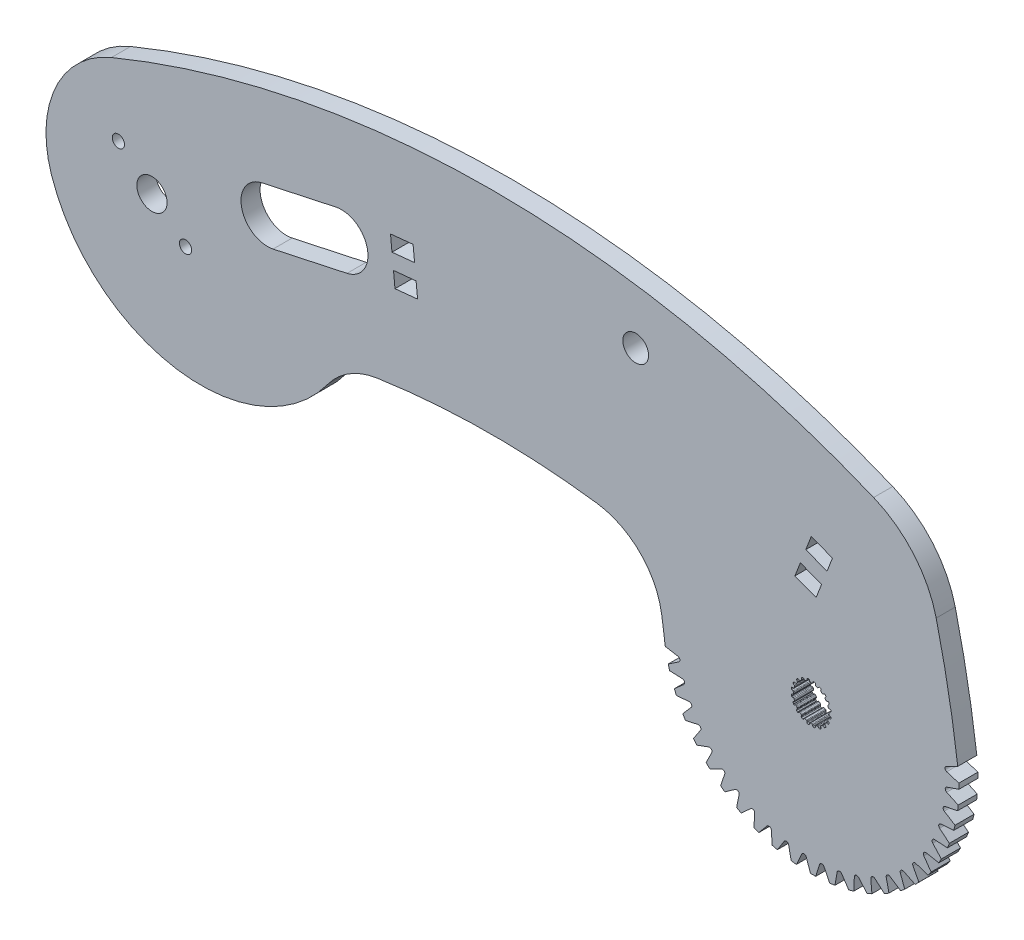
from build123d import *

# Parameters (mm, degrees)
BOSS_EXTRUDE1_DEPTH = 3.2004
BOSS_EXTRUDE2_DEPTH = 3.2004
SKETCH4_R           = 2.54
CUT_EXTRUDE1_DEPTH  = 3.2004
FILLET1_R           = 12.7
SKETCH8_R           = 1.025
CUT_EXTRUDE3_DEPTH  = 3.2004
CUT_EXTRUDE4_DEPTH  = 3.2004
BOSS_EXTRUDE3_DEPTH = 3.2004
CUT_EXTRUDE5_DEPTH  = 3.2004
SKETCH16_R          = 2.159
CUT_EXTRUDE6_DEPTH  = 3.2004


with BuildPart() as part:
    # Sketch1 → Boss-Extrude1 (new body)
    with BuildSketch(Plane.XY):
        with BuildLine():
            ThreePointArc((-6.790095085, 16.435726481), (57.15, 29.123460788), (121.090095085, 16.435726481))
            ThreePointArc((121.090095085, 16.435726481), (130.735726481, -6.790095085), (107.509904915, -16.435726481))
            ThreePointArc((107.509904915, -16.435726481), (57.15, -6.442730812), (6.790095085, -16.435726481))
            ThreePointArc((6.790095085, -16.435726481), (-16.435726481, -6.790095085), (-6.790095085, 16.435726481))
        make_face()
    extrude(amount=BOSS_EXTRUDE1_DEPTH)

    # Sketch3 → Boss-Extrude2 (add)
    with BuildSketch(Plane.XY.offset(3.2004)):
        with BuildLine():
            Line((83.379181354, -7.455358977), (131.587687265, 4.16825686))
            ThreePointArc((131.587687265, 4.16825686), (133.67003564, -5.652924646), (135.206099965, -15.574229365))
            ThreePointArc((135.206099965, -15.574229365), (113.721957777, -43.287328325), (86.008858395, -21.80318668))
            ThreePointArc((86.008858395, -21.80318668), (84.892525498, -14.592890619), (83.379181354, -7.455358977))
        make_face()
    extrude(amount=-BOSS_EXTRUDE2_DEPTH)

    # Sketch4 → Cut-Extrude1 (cut)
    with BuildSketch(Plane.XY.offset(3.2004)):
        Circle(SKETCH4_R)
        with BuildLine():
            Line((110.500529874, -15.718832607), (110.714428364, -15.718832607))
            ThreePointArc((110.714428364, -15.718832607), (110.803822332, -15.701783365), (110.861218357, -15.631160037))
            Line((110.861218357, -15.631160037), (110.923367267, -15.4511806))
            ThreePointArc((110.923367267, -15.4511806), (110.966511275, -15.390384629), (111.035624019, -15.362438535))
            Line((111.035624019, -15.362438535), (111.227506707, -15.394952841))
            ThreePointArc((111.227506707, -15.394952841), (111.297100261, -15.440681781), (111.325751331, -15.51887075))
            Line((111.325751331, -15.51887075), (111.331868286, -15.709180149))
            ThreePointArc((111.331868286, -15.709180149), (111.358413881, -15.784641441), (111.423506169, -15.831139498))
            Line((111.423506169, -15.831139498), (111.626935721, -15.897237766))
            ThreePointArc((111.626935721, -15.897237766), (111.717222943, -15.908647229), (111.793633615, -15.8592168))
            Line((111.793633615, -15.8592168), (111.908357445, -15.707251253))
            ThreePointArc((111.908357445, -15.707251253), (111.968176823, -15.662763081), (112.042542767, -15.657541778))
            Line((112.042542767, -15.657541778), (112.214986574, -15.747759732))
            ThreePointArc((112.214986574, -15.747759732), (112.267042958, -15.812756129), (112.270130024, -15.895971925))
            Line((112.270130024, -15.895971925), (112.217138755, -16.078857163))
            ThreePointArc((112.217138755, -16.078857163), (112.219066295, -16.158828156), (112.26660405, -16.223165059))
            Line((112.26660405, -16.223165059), (112.439651563, -16.348891437))
            ThreePointArc((112.439651563, -16.348891437), (112.521994096, -16.387642766), (112.609939806, -16.364243831))
            Line((112.609939806, -16.364243831), (112.766008588, -16.25516762))
            ThreePointArc((112.766008588, -16.25516762), (112.8366478, -16.231342059), (112.908987486, -16.249356646))
            Line((112.908987486, -16.249356646), (113.045112412, -16.388447085))
            ThreePointArc((113.045112412, -16.388447085), (113.074535984, -16.46634864), (113.051756863, -16.546445521))
            Line((113.051756863, -16.546445521), (112.944844525, -16.704004515))
            ThreePointArc((112.944844525, -16.704004515), (112.921965328, -16.780657092), (112.947295223, -16.856535097))
            Line((112.947295223, -16.856535097), (113.073021601, -17.02958261))
            ThreePointArc((113.073021601, -17.02958261), (113.139359184, -17.091882556), (113.230231193, -17.096805566))
            Line((113.230231193, -17.096805566), (113.412367828, -17.041295831))
            ThreePointArc((113.412367828, -17.041295831), (113.486912214, -17.040465092), (113.55014453, -17.079952174))
            Line((113.55014453, -17.079952174), (113.636625719, -17.254299959))
            ThreePointArc((113.636625719, -17.254299959), (113.640536294, -17.337481124), (113.594120765, -17.406618649))
            Line((113.594120765, -17.406618649), (113.443752683, -17.523428428))
            ThreePointArc((113.443752683, -17.523428428), (113.398306325, -17.5892593), (113.398948893, -17.669250939))
            Line((113.398948893, -17.669250939), (113.465047162, -17.872680491))
            ThreePointArc((113.465047162, -17.872680491), (113.50888621, -17.952430701), (113.593789333, -17.985193757))
            Line((113.593789333, -17.985193757), (113.784165019, -17.988684177))
            ThreePointArc((113.784165019, -17.988684177), (113.855317655, -18.01092958), (113.903252982, -18.068023887))
            Line((113.903252982, -18.068023887), (113.931625051, -18.260562641))
            ThreePointArc((113.931625051, -18.260562641), (113.909639836, -18.340881064), (113.844131375, -18.392291571))
            Line((113.844131375, -18.392291571), (113.665026623, -18.456917979))
            ThreePointArc((113.665026623, -18.456917979), (113.60146171, -18.505483162), (113.577354053, -18.581758296))
            Line((113.577354053, -18.581758296), (113.577354053, -18.795656786))
            ThreePointArc((113.577354053, -18.795656786), (113.594403295, -18.885050754), (113.665026623, -18.942446779))
            Line((113.665026623, -18.942446779), (113.84500606, -19.004595688))
            ThreePointArc((113.84500606, -19.004595688), (113.90580203, -19.047739697), (113.933748125, -19.116852441))
            Line((113.933748125, -19.116852441), (113.901233819, -19.308735128))
            ThreePointArc((113.901233819, -19.308735128), (113.855504879, -19.378328683), (113.77731591, -19.406979753))
            Line((113.77731591, -19.406979753), (113.58700651, -19.413096707))
            ThreePointArc((113.58700651, -19.413096707), (113.511545219, -19.439642303), (113.465047162, -19.50473459))
            Line((113.465047162, -19.50473459), (113.398948893, -19.708164143))
            ThreePointArc((113.398948893, -19.708164143), (113.387539431, -19.798451364), (113.43696986, -19.874862037))
            Line((113.43696986, -19.874862037), (113.588935407, -19.989585866))
            ThreePointArc((113.588935407, -19.989585866), (113.633423579, -20.049405245), (113.638644882, -20.123771188))
            Line((113.638644882, -20.123771188), (113.548426928, -20.296214996))
            ThreePointArc((113.548426928, -20.296214996), (113.483430531, -20.34827138), (113.400214734, -20.351358446))
            Line((113.400214734, -20.351358446), (113.217329497, -20.298367177))
            ThreePointArc((113.217329497, -20.298367177), (113.137358504, -20.300294717), (113.073021601, -20.347832471))
            Line((113.073021601, -20.347832471), (112.947295223, -20.520879985))
            ThreePointArc((112.947295223, -20.520879985), (112.908543894, -20.603222517), (112.931942829, -20.691168228))
            Line((112.931942829, -20.691168228), (113.04101904, -20.84723701))
            ThreePointArc((113.04101904, -20.84723701), (113.064844601, -20.917876221), (113.046830014, -20.990215907))
            Line((113.046830014, -20.990215907), (112.907739575, -21.126340834))
            ThreePointArc((112.907739575, -21.126340834), (112.82983802, -21.155764405), (112.749741139, -21.132985285))
            Line((112.749741139, -21.132985285), (112.592182145, -21.026072946))
            ThreePointArc((112.592182145, -21.026072946), (112.515529568, -21.00319375), (112.439651563, -21.028523645))
            Line((112.439651563, -21.028523645), (112.26660405, -21.154250022))
            ThreePointArc((112.26660405, -21.154250022), (112.204304104, -21.220587605), (112.199381094, -21.311459615))
            Line((112.199381094, -21.311459615), (112.254890829, -21.49359625))
            ThreePointArc((112.254890829, -21.49359625), (112.255721568, -21.568140636), (112.216234486, -21.631372952))
            Line((112.216234486, -21.631372952), (112.041886701, -21.71785414))
            ThreePointArc((112.041886701, -21.71785414), (111.958705536, -21.721764716), (111.889568011, -21.675349187))
            Line((111.889568011, -21.675349187), (111.772758232, -21.524981105))
            ThreePointArc((111.772758232, -21.524981105), (111.70692736, -21.479534747), (111.626935721, -21.480177315))
            Line((111.626935721, -21.480177315), (111.423506169, -21.546275584))
            ThreePointArc((111.423506169, -21.546275584), (111.343755958, -21.590114632), (111.310992903, -21.675017755))
            Line((111.310992903, -21.675017755), (111.307502483, -21.86539344))
            ThreePointArc((111.307502483, -21.86539344), (111.28525708, -21.936546076), (111.228162773, -21.984481404))
            Line((111.228162773, -21.984481404), (111.035624019, -22.012853473))
            ThreePointArc((111.035624019, -22.012853473), (110.955305596, -21.990868258), (110.903895089, -21.925359796))
            Line((110.903895089, -21.925359796), (110.839268681, -21.746255045))
            ThreePointArc((110.839268681, -21.746255045), (110.790703498, -21.682690132), (110.714428364, -21.658582475))
            Line((110.714428364, -21.658582475), (110.500529874, -21.658582475))
            ThreePointArc((110.500529874, -21.658582475), (110.411135906, -21.675631717), (110.353739881, -21.746255045))
            Line((110.353739881, -21.746255045), (110.291590972, -21.926234482))
            ThreePointArc((110.291590972, -21.926234482), (110.248446963, -21.987030452), (110.179334219, -22.014976546))
            Line((110.179334219, -22.014976546), (109.987451531, -21.982462241))
            ThreePointArc((109.987451531, -21.982462241), (109.917857977, -21.936733301), (109.889206907, -21.858544331))
            Line((109.889206907, -21.858544331), (109.883089953, -21.668234932))
            ThreePointArc((109.883089953, -21.668234932), (109.856544357, -21.59277364), (109.79145207, -21.546275584))
            Line((109.79145207, -21.546275584), (109.588022517, -21.480177315))
            ThreePointArc((109.588022517, -21.480177315), (109.497735296, -21.468767853), (109.421324623, -21.518198282))
            Line((109.421324623, -21.518198282), (109.306600794, -21.670163829))
            ThreePointArc((109.306600794, -21.670163829), (109.246781415, -21.714652001), (109.172415471, -21.719873303))
            Line((109.172415471, -21.719873303), (108.999971664, -21.62965535))
            ThreePointArc((108.999971664, -21.62965535), (108.94791528, -21.564658952), (108.944828214, -21.481443156))
            Line((108.944828214, -21.481443156), (108.997819483, -21.298557919))
            ThreePointArc((108.997819483, -21.298557919), (108.995891943, -21.218586925), (108.948354188, -21.154250022))
            Line((108.948354188, -21.154250022), (108.775306675, -21.028523645))
            ThreePointArc((108.775306675, -21.028523645), (108.692964143, -20.989772315), (108.605018432, -21.01317125))
            Line((108.605018432, -21.01317125), (108.44894965, -21.122247461))
            ThreePointArc((108.44894965, -21.122247461), (108.378310439, -21.146073022), (108.305970752, -21.128058436))
            Line((108.305970752, -21.128058436), (108.169845826, -20.988967996))
            ThreePointArc((108.169845826, -20.988967996), (108.140422255, -20.911066442), (108.163201375, -20.830969561))
            Line((108.163201375, -20.830969561), (108.270113713, -20.673410567))
            ThreePointArc((108.270113713, -20.673410567), (108.29299291, -20.59675799), (108.267663015, -20.520879985))
            Line((108.267663015, -20.520879985), (108.141936637, -20.347832471))
            ThreePointArc((108.141936637, -20.347832471), (108.075599055, -20.285532525), (107.984727045, -20.280609516))
            Line((107.984727045, -20.280609516), (107.80259041, -20.336119251))
            ThreePointArc((107.80259041, -20.336119251), (107.728046024, -20.336949989), (107.664813708, -20.297462907))
            Line((107.664813708, -20.297462907), (107.578332519, -20.123115123))
            ThreePointArc((107.578332519, -20.123115123), (107.574421944, -20.039933958), (107.620837473, -19.970796432))
            Line((107.620837473, -19.970796432), (107.771205555, -19.853986654))
            ThreePointArc((107.771205555, -19.853986654), (107.816651913, -19.788155782), (107.816009345, -19.708164143))
            Line((107.816009345, -19.708164143), (107.749911076, -19.50473459))
            ThreePointArc((107.749911076, -19.50473459), (107.706072028, -19.42498438), (107.621168905, -19.392221324))
            Line((107.621168905, -19.392221324), (107.430793219, -19.388730904))
            ThreePointArc((107.430793219, -19.388730904), (107.359640584, -19.366485502), (107.311705256, -19.309391194))
            Line((107.311705256, -19.309391194), (107.283333187, -19.116852441))
            ThreePointArc((107.283333187, -19.116852441), (107.305318402, -19.036534018), (107.370826864, -18.985123511))
            Line((107.370826864, -18.985123511), (107.549931615, -18.920497103))
            ThreePointArc((107.549931615, -18.920497103), (107.613496528, -18.87193192), (107.637604185, -18.795656786))
            Line((107.637604185, -18.795656786), (107.637604185, -18.581758296))
            ThreePointArc((107.637604185, -18.581758296), (107.620554943, -18.492364328), (107.549931615, -18.434968302))
            Line((107.549931615, -18.434968302), (107.369952178, -18.372819393))
            ThreePointArc((107.369952178, -18.372819393), (107.309156208, -18.329675384), (107.281210114, -18.260562641))
            Line((107.281210114, -18.260562641), (107.313724419, -18.068679953))
            ThreePointArc((107.313724419, -18.068679953), (107.359453359, -17.999086399), (107.437642328, -17.970435329))
            Line((107.437642328, -17.970435329), (107.627951728, -17.964318374))
            ThreePointArc((107.627951728, -17.964318374), (107.70341302, -17.937772779), (107.749911076, -17.872680491))
            Line((107.749911076, -17.872680491), (107.816009345, -17.669250939))
            ThreePointArc((107.816009345, -17.669250939), (107.827418807, -17.578963717), (107.777988378, -17.502553045))
            Line((107.777988378, -17.502553045), (107.626022831, -17.387829215))
            ThreePointArc((107.626022831, -17.387829215), (107.581534659, -17.328009836), (107.576313357, -17.253643893))
            Line((107.576313357, -17.253643893), (107.66653131, -17.081200086))
            ThreePointArc((107.66653131, -17.081200086), (107.731527707, -17.029143702), (107.814743504, -17.026056635))
            Line((107.814743504, -17.026056635), (107.997628741, -17.079047904))
            ThreePointArc((107.997628741, -17.079047904), (108.077599734, -17.077120365), (108.141936637, -17.02958261))
            Line((108.141936637, -17.02958261), (108.267663015, -16.856535097))
            ThreePointArc((108.267663015, -16.856535097), (108.306414345, -16.774192564), (108.28301541, -16.686246854))
            Line((108.28301541, -16.686246854), (108.173939199, -16.530178071))
            ThreePointArc((108.173939199, -16.530178071), (108.150113637, -16.45953886), (108.168128224, -16.387199174))
            Line((108.168128224, -16.387199174), (108.307218664, -16.251074248))
            ThreePointArc((108.307218664, -16.251074248), (108.385120218, -16.221650676), (108.465217099, -16.244429797))
            Line((108.465217099, -16.244429797), (108.622776093, -16.351342135))
            ThreePointArc((108.622776093, -16.351342135), (108.69942867, -16.374221332), (108.775306675, -16.348891437))
            Line((108.775306675, -16.348891437), (108.948354188, -16.223165059))
            ThreePointArc((108.948354188, -16.223165059), (109.010654135, -16.156827476), (109.015577144, -16.065955467))
            Line((109.015577144, -16.065955467), (108.960067409, -15.883818831))
            ThreePointArc((108.960067409, -15.883818831), (108.95923667, -15.809274446), (108.998723753, -15.746042129))
            Line((108.998723753, -15.746042129), (109.173071537, -15.659560941))
            ThreePointArc((109.173071537, -15.659560941), (109.256252702, -15.655650366), (109.325390227, -15.702065894))
            Line((109.325390227, -15.702065894), (109.442200006, -15.852433977))
            ThreePointArc((109.442200006, -15.852433977), (109.508030878, -15.897880335), (109.588022517, -15.897237766))
            Line((109.588022517, -15.897237766), (109.79145207, -15.831139498))
            ThreePointArc((109.79145207, -15.831139498), (109.87120228, -15.78730045), (109.903965335, -15.702397326))
            Line((109.903965335, -15.702397326), (109.907455756, -15.512021641))
            ThreePointArc((109.907455756, -15.512021641), (109.929701158, -15.440869005), (109.986795466, -15.392933678))
            Line((109.986795466, -15.392933678), (110.179334219, -15.364561609))
            ThreePointArc((110.179334219, -15.364561609), (110.259652642, -15.386546824), (110.311063149, -15.452055285))
            Line((110.311063149, -15.452055285), (110.375689557, -15.631160037))
            ThreePointArc((110.375689557, -15.631160037), (110.42425474, -15.69472495), (110.500529874, -15.718832607))
        make_face()
    extrude(amount=-CUT_EXTRUDE1_DEPTH, mode=Mode.SUBTRACT)

    # Fillet1
    fillet1_edges = [part.edges().sort_by_distance(p)[0] for p in [
        (83.777939846, -9.158691557, 1.6002),
    ]]
    fillet(fillet1_edges, radius=FILLET1_R)

    # Sketch8 → Cut-Extrude3 (cut)
    with BuildSketch(Plane.XY.offset(3.2004)):
        with Locations((-5.638481561, 4.857351801)):
            Circle(SKETCH8_R)
        with Locations((5.638481561, -4.857351801)):
            Circle(SKETCH8_R)
    extrude(amount=-CUT_EXTRUDE3_DEPTH, mode=Mode.SUBTRACT)

    # Sketch9 → Cut-Extrude4 (cut)
    with BuildSketch(Plane(origin=(0, 0, 0), x_dir=(-1, 0, 0), z_dir=(0, 0, -1))):
        with BuildLine():
            Line((-32.737355568, 4.832999456), (-20.323370494, 2.152892259))
            ThreePointArc((-20.323370494, 2.152892259), (-15.040438199, 5.559749516), (-18.447295456, 10.842681811))
            Line((-18.447295456, 10.842681811), (-30.86128053, 13.522789008))
            ThreePointArc((-30.86128053, 13.522789008), (-36.144212825, 10.115931751), (-32.737355568, 4.832999456))
        make_face()
        Polygon((-43.813768875, 14.581742769), (-40.022576906, 14.203637681), (-40.274646964, 11.676176369), (-44.065838933, 12.054281456), align=None)
        Polygon((-44.317908991, 9.526820144), (-40.526717023, 9.148715056), (-40.778787081, 6.621253744), (-44.56997905, 6.999358831), align=None)
        Polygon((-114.181857227, 4.17371566), (-110.627310604, 5.545319942), (-109.712907749, 3.175622193), (-113.267454372, 1.804017911), align=None)
        Polygon((-112.353051517, -0.565679837), (-108.798504894, 0.805924445), (-107.88410204, -1.563773304), (-111.438648663, -2.935377586), align=None)
    extrude(amount=-CUT_EXTRUDE4_DEPTH, mode=Mode.SUBTRACT)

    # Sketch10 → Boss-Extrude3 (add)
    with BuildSketch(Plane(origin=(0, 0, 0), x_dir=(-1, 0, 0), z_dir=(0, 0, -1))):
        with BuildLine():
            Line((-37.808873064, -7.868571576), (16.868359085, -5.630005154))
            ThreePointArc((16.868359085, -5.630005154), (-4.132336455, -23.377701749), (-29.538208471, -12.863348953))
            ThreePointArc((-29.538208471, -12.863348953), (-33.172339638, -9.536040105), (-37.808873064, -7.868571576))
        make_face()
    extrude(amount=-BOSS_EXTRUDE3_DEPTH)

    # Sketch15 → Cut-Extrude5 (cut)
    with BuildSketch(Plane.XY.offset(3.2004)):
        with BuildLine():
            Line((135.206099965, -15.574229365), (133.293366055, -16.522564433))
            ThreePointArc((133.293366055, -16.522564433), (133.066567566, -16.922363506), (133.353077191, -17.281792342))
            Line((133.353077191, -17.281792342), (135.390545365, -17.919455144))
            ThreePointArc((135.390545365, -17.919455144), (135.326151737, -16.744653577), (135.206099965, -15.574229365))
        make_face()
        with BuildLine():
            Line((135.40217633, -18.811638471), (133.382023559, -19.502198526))
            ThreePointArc((133.382023559, -19.502198526), (133.104981112, -19.86897412), (133.34212473, -20.262725003))
            Line((133.34212473, -20.262725003), (135.278930384, -21.160875474))
            ThreePointArc((135.278930384, -21.160875474), (135.368430028, -19.987719441), (135.40217633, -18.811638471))
        make_face()
        with BuildLine():
            Line((135.174008552, -22.046944194), (133.081002294, -22.467913563))
            ThreePointArc((133.081002294, -22.467913563), (132.758456162, -22.795390045), (132.94217618, -23.216725789))
            Line((132.94217618, -23.216725789), (134.745180032, -24.359996325))
            ThreePointArc((134.745180032, -24.359996325), (134.987041583, -23.208558852), (135.174008552, -22.046944194))
        make_face()
        with BuildLine():
            Line((134.525500645, -25.224789557), (132.395452816, -25.368965338))
            ThreePointArc((132.395452816, -25.368965338), (132.032921852, -25.651539495), (132.16007477, -26.093250926))
            Line((132.16007477, -26.093250926), (133.798426924, -27.462079852))
            ThreePointArc((133.798426924, -27.462079852), (134.188512066, -26.352062354), (134.525500645, -25.224789557))
        make_face()
        with BuildLine():
            Line((133.467748757, -28.290800744), (131.337105067, -28.155716049))
            ThreePointArc((131.337105067, -28.155716049), (130.940792278, -28.388552958), (131.009202473, -28.843082274))
            Line((131.009202473, -28.843082274), (132.45487027, -30.414048547))
            ThreePointArc((132.45487027, -30.414048547), (132.986504536, -29.364443731), (133.467748757, -28.290800744))
        make_face()
        with BuildLine():
            Line((132.018851318, -31.192517455), (129.924067671, -30.78048362))
            ThreePointArc((129.924067671, -30.78048362), (129.500754077, -30.959599378), (129.509251033, -31.419169455))
            Line((129.509251033, -31.419169455), (130.737498696, -33.165393406))
            ThreePointArc((130.737498696, -33.165393406), (131.401585677, -32.194160301), (132.018851318, -31.192517455))
        make_face()
        with BuildLine():
            Line((130.203599365, -33.880290511), (128.180518089, -33.19835755))
            ThreePointArc((128.180518089, -33.19835755), (127.737446704, -33.320687436), (127.685885035, -33.777434902))
            Line((127.685885035, -33.777434902), (128.675696906, -35.669038156))
            ThreePointArc((128.675696906, -35.669038156), (129.46087389, -34.79279483), (130.203599365, -33.880290511))
        make_face()
        with BuildLine():
            Line((128.053052361, -36.30813137), (126.136288939, -35.367967345))
            ThreePointArc((126.136288939, -35.367967345), (125.681040837, -35.431418262), (125.570302777, -35.877528042))
            Line((125.570302777, -35.877528042), (126.304742901, -37.882144742))
            ThreePointArc((126.304742901, -37.882144742), (127.197575291, -37.115883961), (128.053052361, -36.30813137))
        make_face()
        with BuildLine():
            Line((125.604006762, -38.434499003), (123.826357547, -37.252190381))
            ThreePointArc((123.826357547, -37.252190381), (123.366722149, -37.255676665), (123.198702458, -37.683515696))
            Line((123.198702458, -37.683515696), (123.665204359, -39.766846296))
            ThreePointArc((123.665204359, -39.766846296), (124.650415547, -39.123678994), (125.604006762, -38.434499003))
        make_face()
        with BuildLine():
            Line((122.898366417, -40.22301067), (121.29024748, -38.818787078))
            ThreePointArc((121.29024748, -38.818787078), (120.834089275, -38.762249078), (120.611662816, -39.164496917))
            Line((120.611662816, -39.164496917), (120.802244519, -41.290895051))
            ThreePointArc((120.802244519, -41.290895051), (121.862977268, -40.781826), (122.898366417, -40.22301067))
        make_face()
        with BuildLine():
            Line((119.982425582, -41.643064439), (118.571352285, -40.040952534))
            ThreePointArc((118.571352285, -40.040952534), (118.126476266, -39.92535763), (117.853448818, -40.295131705))
            Line((117.853448818, -40.295131705), (117.764849416, -42.428214112))
            ThreePointArc((117.764849416, -42.428214112), (118.882954294, -42.061953624), (119.982425582, -41.643064439))
        make_face()
        with BuildLine():
            Line((116.906076815, -42.670362798), (115.716193011, -40.897775157))
            ThreePointArc((115.716193011, -40.897775157), (115.290211131, -40.725101212), (114.971254269, -41.056074585))
            Line((114.971254269, -41.056074585), (114.604989723, -43.159343634))
            ThreePointArc((114.604989723, -43.159343634), (115.761335646, -42.942158527), (116.906076815, -42.670362798))
        make_face()
        with BuildLine():
            Line((113.721957295, -43.287328386), (112.773622227, -41.374594477))
            ThreePointArc((112.773622227, -41.374594477), (112.373823154, -41.147795988), (112.014394318, -41.434305613))
            Line((112.014394318, -41.434305613), (111.376731515, -43.471773787))
            ThreePointArc((111.376731515, -43.471773787), (112.551533083, -43.407380159), (113.721957295, -43.287328386))
        make_face()
        with BuildLine():
            Line((110.484548189, -43.483404752), (109.793988134, -41.463251981))
            ThreePointArc((109.793988134, -41.463251981), (109.42721254, -41.186209534), (109.033461657, -41.423353152))
            Line((109.033461657, -41.423353152), (108.135311186, -43.360158806))
            ThreePointArc((108.135311186, -43.360158806), (109.308467218, -43.449658449), (110.484548189, -43.483404752))
        make_face()
        with BuildLine():
            Line((107.249242466, -43.255236974), (106.828273097, -41.162230715))
            ThreePointArc((106.828273097, -41.162230715), (106.500796615, -40.839684583), (106.079460871, -41.023404601))
            Line((106.079460871, -41.023404601), (104.936190335, -42.826408453))
            ThreePointArc((104.936190335, -42.826408453), (106.087627807, -43.068270005), (107.249242466, -43.255236974))
        make_face()
        with BuildLine():
            Line((104.071397103, -42.606729066), (103.927221322, -40.476681237))
            ThreePointArc((103.927221322, -40.476681237), (103.644647165, -40.114150274), (103.202935733, -40.241303192))
            Line((103.202935733, -40.241303192), (101.834106808, -41.879655346))
            ThreePointArc((101.834106808, -41.879655346), (102.944124306, -42.269740487), (104.071397103, -42.606729066))
        make_face()
        with BuildLine():
            Line((101.005385916, -41.548977179), (101.140470611, -39.418333489))
            ThreePointArc((101.140470611, -39.418333489), (100.907633701, -39.022020699), (100.453104386, -39.090430895))
            Line((100.453104386, -39.090430895), (98.882138113, -40.536098692))
            ThreePointArc((98.882138113, -40.536098692), (99.931742929, -41.067732958), (101.005385916, -41.548977179))
        make_face()
        with BuildLine():
            Line((98.103669205, -40.10007974), (98.51570304, -38.005296093))
            ThreePointArc((98.51570304, -38.005296093), (98.336587282, -37.581982499), (97.877017205, -37.590479455))
            Line((97.877017205, -37.590479455), (96.130793254, -38.818727118))
            ThreePointArc((96.130793254, -38.818727118), (97.102026359, -39.482814099), (98.103669205, -40.10007974))
        make_face()
        with BuildLine():
            Line((95.415896149, -38.284827786), (96.09782911, -36.261746511))
            ThreePointArc((96.09782911, -36.261746511), (95.975499224, -35.818675126), (95.518751757, -35.767113457))
            Line((95.518751757, -35.767113457), (93.627148504, -36.756925328))
            ThreePointArc((93.627148504, -36.756925328), (94.50339183, -37.542102312), (95.415896149, -38.284827786))
        make_face()
        with BuildLine():
            Line((92.988055289, -36.134280782), (93.928219315, -34.217517361))
            ThreePointArc((93.928219315, -34.217517361), (93.864768398, -33.762269258), (93.418658618, -33.651531199))
            Line((93.418658618, -33.651531199), (91.414041918, -34.385971322))
            ThreePointArc((91.414041918, -34.385971322), (92.180302699, -35.278803713), (92.988055289, -36.134280782))
        make_face()
        with BuildLine():
            Line((90.861687656, -33.685235183), (92.043996279, -31.907585969))
            ThreePointArc((92.043996279, -31.907585969), (92.040509995, -31.44795057), (91.612670964, -31.27993088))
            Line((91.612670964, -31.27993088), (89.529340364, -31.746432781))
            ThreePointArc((89.529340364, -31.746432781), (90.172507666, -32.731643969), (90.861687656, -33.685235183))
        make_face()
        with BuildLine():
            Line((89.07317599, -30.979594838), (90.477399582, -29.371475902))
            ThreePointArc((90.477399582, -29.371475902), (90.533937582, -28.915317697), (90.131689743, -28.692891238))
            Line((90.131689743, -28.692891238), (88.005291609, -28.883472941))
            ThreePointArc((88.005291609, -28.883472941), (88.51436066, -29.944205689), (89.07317599, -30.979594838))
        make_face()
        with BuildLine():
            Line((87.653122221, -28.063654004), (89.255234126, -26.652580706))
            ThreePointArc((89.255234126, -26.652580706), (89.370829029, -26.207704688), (89.001054955, -25.93467724))
            Line((89.001054955, -25.93467724), (86.867972548, -25.846077838))
            ThreePointArc((86.867972548, -25.846077838), (87.234233036, -26.964182716), (87.653122221, -28.063654004))
        make_face()
        with BuildLine():
            Line((86.625823862, -24.987305237), (88.398411502, -23.797421433))
            ThreePointArc((88.398411502, -23.797421433), (88.571085448, -23.371439553), (88.240112075, -23.052482691))
            Line((88.240112075, -23.052482691), (86.136843026, -22.686218145))
            ThreePointArc((86.136843026, -22.686218145), (86.354028133, -23.842564067), (86.625823862, -24.987305237))
        make_face()
    extrude(amount=-CUT_EXTRUDE5_DEPTH, mode=Mode.SUBTRACT)

    # Sketch16 → Cut-Extrude6 (cut)
    with BuildSketch(Plane(origin=(0, 0, 0), x_dir=(-1, 0, 0), z_dir=(0, 0, -1))):
        with Locations((-81.171495518, 18.191790938)):
            Circle(SKETCH16_R)
    extrude(amount=-CUT_EXTRUDE6_DEPTH, mode=Mode.SUBTRACT)


solid = part.part
